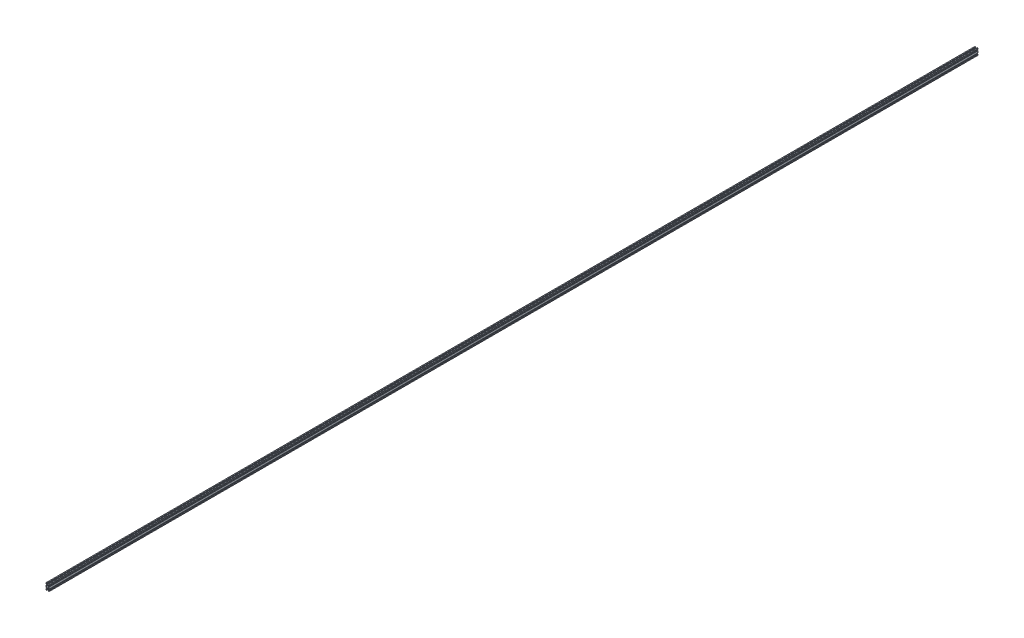
from build123d import *

# Parameters (mm, degrees)
EXTRUS_O1_DEPTH = 6000


with BuildPart() as part:
    # Sketch1 → Extrusão1 (new body)
    with BuildSketch(Plane.XY):
        Polygon((-4, -18.5), (-4, -20), (-10, -20), (-10, -14), (-8.5, -14), (-8.5, -17.527218), (-4, -13.027218), (-4, -6.972782), (-8.5, -2.472782), (-8.5, -6), (-10, -6), (-10, 6), (-8.5, 6), (-8.5, 2.472782), (-4, 6.972782), (-4, 13.027218), (-8.5, 17.527218), (-8.5, 14), (-10, 14), (-10, 20), (-4, 20), (-4, 18.5), (-7.527218, 18.5), (-3.027218, 14), (3.027218, 14), (7.527218, 18.5), (4, 18.5), (4, 20), (10, 20), (10, 14), (8.5, 14), (8.5, 17.527218), (4, 13.027218), (4, 6.972782), (8.5, 2.472782), (8.5, 6), (10, 6), (10, -6), (8.5, -6), (8.5, -2.472782), (4, -6.972782), (4, -13.027218), (8.5, -17.527218), (8.5, -14), (10, -14), (10, -20), (4, -20), (4, -18.5), (7.527218, -18.5), (3.027218, -14), (-3.027218, -14), (-7.527218, -18.5), align=None)
        with BuildLine():
            Line((-3.93933851, -4.999999999), (-1.560125514, -2.620783714))
            ThreePointArc((-1.560125514, -2.620783714), (-2.156676048, -2.156676048), (-2.620783714, -1.560125514))
            Line((-2.620783714, -1.560125514), (-5.000000183, -3.939338694))
            Line((-5.000000183, -3.939338694), (-8.939340246, 0))
            Line((-8.939340246, 0), (-5.000000183, 3.939338694))
            Line((-5.000000183, 3.939338694), (-2.620783714, 1.560125514))
            ThreePointArc((-2.620783714, 1.560125514), (-2.156676048, 2.156676048), (-1.560125514, 2.620783714))
            Line((-1.560125514, 2.620783714), (-3.93933851, 4.999999999))
            Line((-3.93933851, 4.999999999), (-1.560122936, 7.379214746))
            ThreePointArc((-1.560122936, 7.379214746), (0, 13.050000275), (1.560122936, 7.379214746))
            Line((1.560122936, 7.379214746), (3.93933851, 4.999999999))
            Line((3.93933851, 4.999999999), (1.560125514, 2.620783714))
            ThreePointArc((1.560125514, 2.620783714), (2.156676048, 2.156676048), (2.620783714, 1.560125514))
            Line((2.620783714, 1.560125514), (5.000000183, 3.939338694))
            Line((5.000000183, 3.939338694), (8.939340246, 0))
            Line((8.939340246, 0), (5.000000183, -3.939338694))
            Line((5.000000183, -3.939338694), (2.620783714, -1.560125514))
            ThreePointArc((2.620783714, -1.560125514), (2.156676048, -2.156676048), (1.560125514, -2.620783714))
            Line((1.560125514, -2.620783714), (3.93933851, -4.999999999))
            Line((3.93933851, -4.999999999), (1.560122936, -7.379214746))
            ThreePointArc((1.560122936, -7.379214746), (0, -13.050000275), (-1.560122936, -7.379214746))
            Line((-1.560122936, -7.379214746), (-3.93933851, -4.999999999))
        make_face(mode=Mode.SUBTRACT)
    extrude(amount=EXTRUS_O1_DEPTH)


solid = part.part
